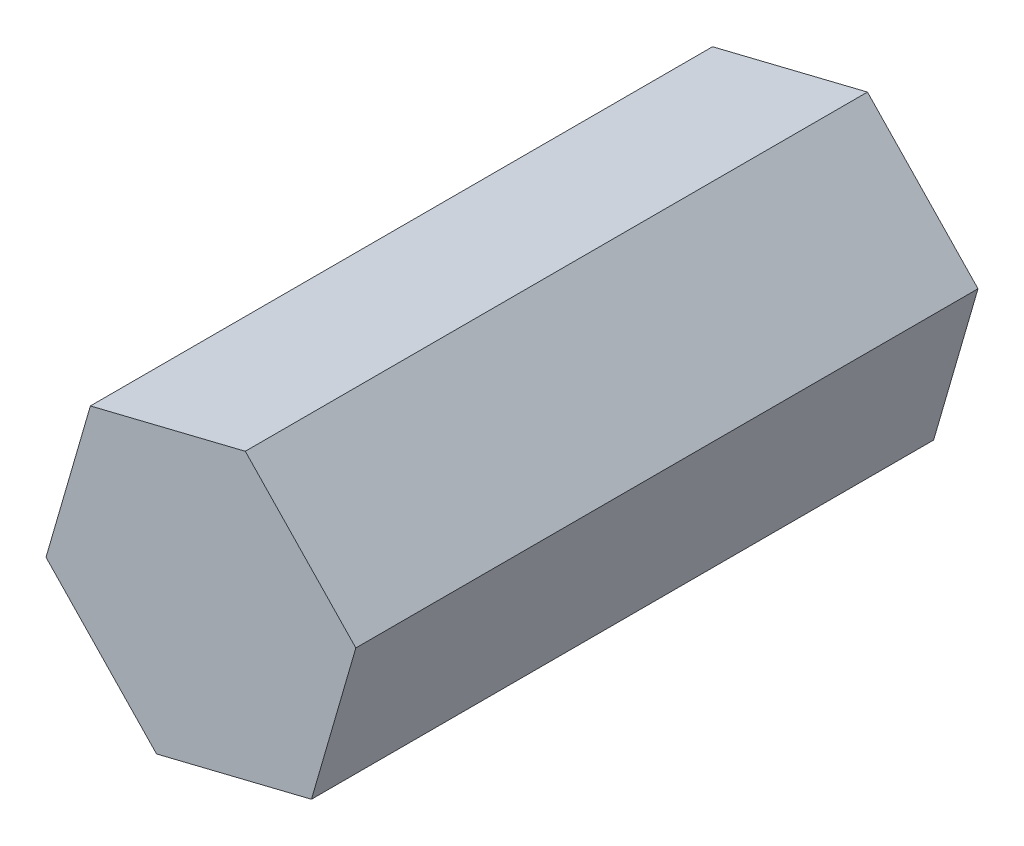
from build123d import *

# Parameters (mm, degrees)
BOSS_EXTRUDE1_DEPTH = 15


with BuildPart() as part:
    # Sketch1 → Boss-Extrude1 (new body)
    with BuildSketch(Plane.XY):
        Polygon((-83.985055254, 18.464818175), (-87.720041989, 17.544012754), (-88.790094471, 13.849016647), (-86.125160216, 11.074825962), (-82.390173481, 11.995631383), (-81.320120999, 15.690627489), align=None)
    extrude(amount=BOSS_EXTRUDE1_DEPTH)


solid = part.part
